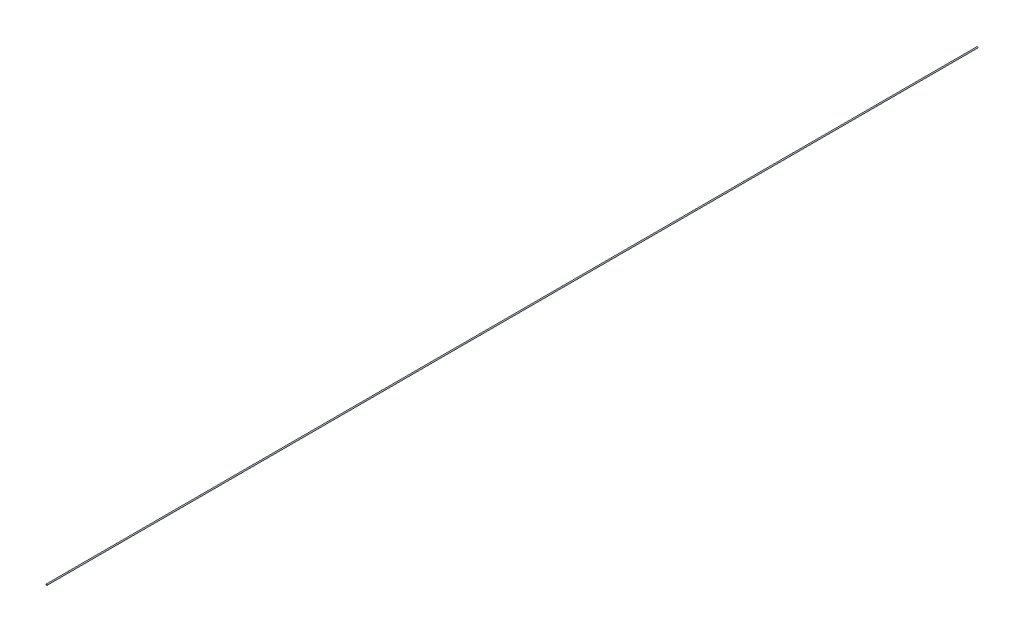
from build123d import *

# Parameters (mm, degrees)
SKETCH1_R = 0.25


with BuildPart() as part:
    # Sweep1: sweep along a path in Sketch2
    with BuildLine(Plane(origin=(0, 0, 0), x_dir=(1, 0, 0), z_dir=(0, 1, 0))) as sweep1_path:
        Line((0, 0), (0, 400))
    # Sketch1 → Sweep1 (sweep)
    with BuildSketch(Plane.XY):
        Circle(SKETCH1_R)
    sweep(path=sweep1_path.line)


solid = part.part
